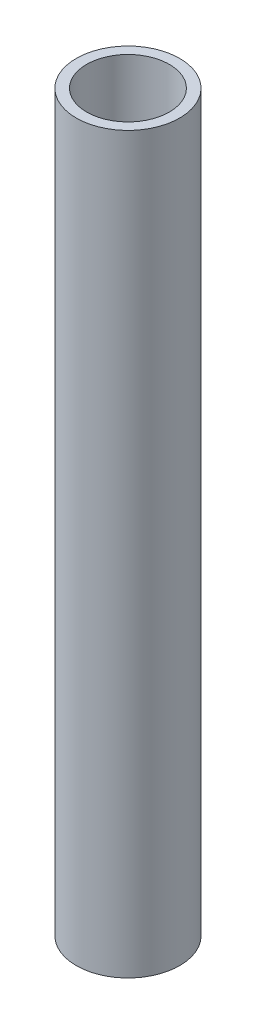
from build123d import *

# Parameters (mm, degrees)
CROQUIS1_R              = 5
CROQUIS1_R_2            = 4
SALIENTE_EXTRUIR1_DEPTH = 71


with BuildPart() as part:
    # Croquis1 → Saliente-Extruir1 (new body)
    with BuildSketch(Plane(origin=(0, 0, 0), x_dir=(1, 0, 0), z_dir=(0, 1, 0))):
        Circle(CROQUIS1_R)
        Circle(CROQUIS1_R_2, mode=Mode.SUBTRACT)
    extrude(amount=SALIENTE_EXTRUIR1_DEPTH)


solid = part.part
